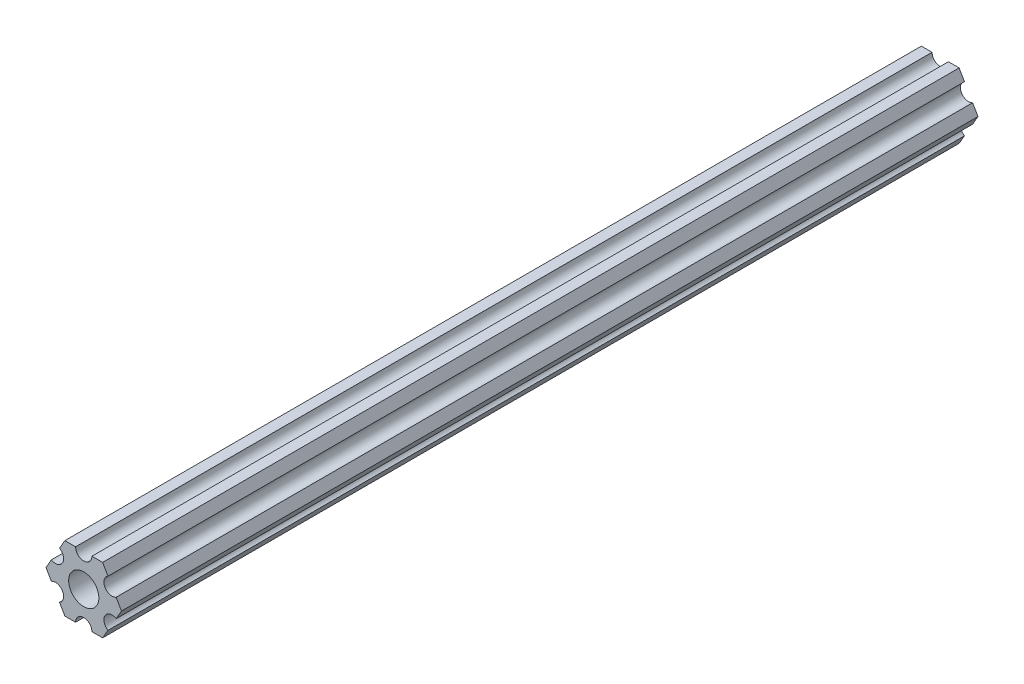
from build123d import *

# Parameters (mm, degrees)
SKETCH1_R           = 2.9337
BOSS_EXTRUDE1_DEPTH = 166.37


with BuildPart() as part:
    # Sketch1 → Boss-Extrude1 (new body)
    with BuildSketch(Plane(origin=(0, 0, 0), x_dir=(-1, 0, 0), z_dir=(0, 0, -1))):
        with BuildLine():
            Line((-4.70551159, -4.549815043), (-3.666174546, -6.349999862))
            Line((-3.666174546, -6.349999862), (-1.587500385, -6.349999862))
            ThreePointArc((-1.587500385, -6.349999862), (-3.85e-07, -4.762499862), (1.587499615, -6.349999862))
            Line((1.587499615, -6.349999862), (3.666173825, -6.349999862))
            Line((3.666173825, -6.349999862), (4.705510942, -4.549815198))
            ThreePointArc((4.705510942, -4.549815198), (4.124445629, -2.381249865), (6.293010962, -1.800184552))
            Line((6.293010962, -1.800184552), (7.332348079, 1.12e-07))
            Line((7.332348079, 1.12e-07), (6.293011217, 1.800184727))
            ThreePointArc((6.293011217, 1.800184727), (4.124445939, 2.381250245), (4.705511457, 4.549815523))
            Line((4.705511457, 4.549815523), (3.666174546, 6.350000222))
            Line((3.666174546, 6.350000222), (1.587500385, 6.350000222))
            ThreePointArc((1.587500385, 6.350000222), (3.85e-07, 4.762500222), (-1.587499615, 6.350000222))
            Line((-1.587499615, 6.350000222), (-3.666173825, 6.350000222))
            Line((-3.666173825, 6.350000222), (-4.705511038, 4.549815614))
            ThreePointArc((-4.705511038, 4.549815614), (-4.124445841, 2.38125025), (-6.293011205, 1.800185053))
            Line((-6.293011205, 1.800185053), (-7.332348419, 4.44e-07))
            Line((-7.332348419, 4.44e-07), (-6.293011423, -1.80018429))
            ThreePointArc((-6.293011423, -1.80018429), (-4.12444613, -2.38124975), (-4.70551159, -4.549815043))
        make_face()
        Circle(SKETCH1_R, mode=Mode.SUBTRACT)
    extrude(amount=-BOSS_EXTRUDE1_DEPTH)


solid = part.part
